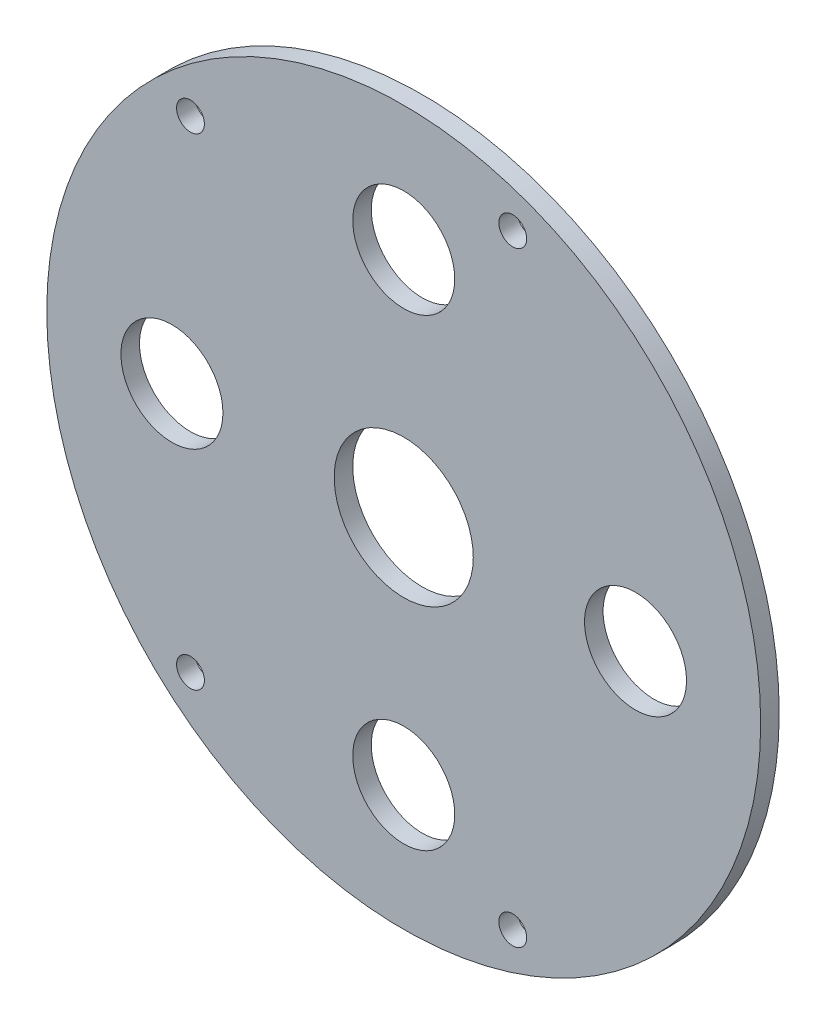
from build123d import *

# Parameters (mm, degrees)
MODEL_R             = 38.5
MODEL_R_2           = 1.5
MODEL_R_3           = 5.5
MODEL_R_4           = 7.5
BOSS_EXTRUDE1_DEPTH = 2


with BuildPart() as part:
    # Model → Boss-Extrude1 (new body)
    with BuildSketch(Plane.XY):
        Circle(MODEL_R)
        with Locations((-23, 25.98)):
            Circle(MODEL_R_2, mode=Mode.SUBTRACT)
        with Locations((11.757144545, -32.646126143)):
            Circle(MODEL_R_2, mode=Mode.SUBTRACT)
        with Locations((11.757144545, 32.646126143)):
            Circle(MODEL_R_2, mode=Mode.SUBTRACT)
        with Locations((-23, -25.98)):
            Circle(MODEL_R_2, mode=Mode.SUBTRACT)
        with Locations((-25, 0)):
            Circle(MODEL_R_3, mode=Mode.SUBTRACT)
        with Locations((0, 25)):
            Circle(MODEL_R_3, mode=Mode.SUBTRACT)
        with Locations((0, -25)):
            Circle(MODEL_R_3, mode=Mode.SUBTRACT)
        with Locations((25, 0)):
            Circle(MODEL_R_3, mode=Mode.SUBTRACT)
        Circle(MODEL_R_4, mode=Mode.SUBTRACT)
    extrude(amount=BOSS_EXTRUDE1_DEPTH)


solid = part.part
